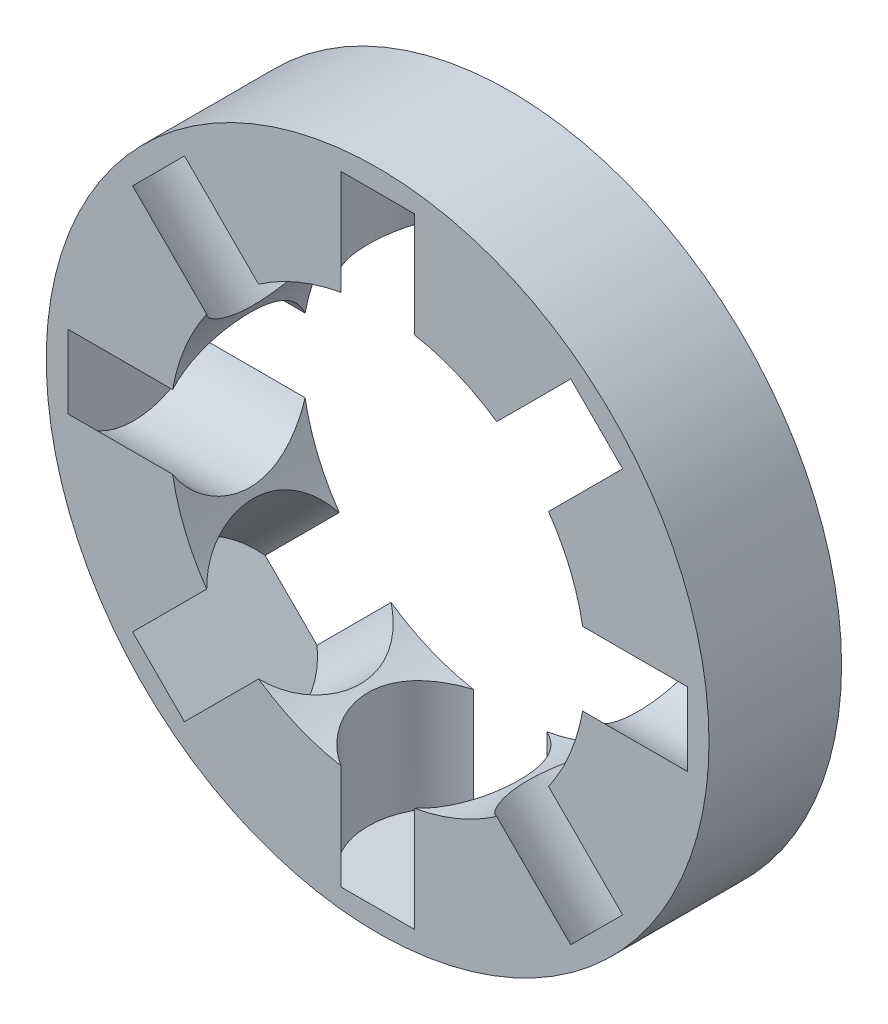
from build123d import *

# Parameters (mm, degrees)
SKETCH1_R           = 17.5
SKETCH1_R_2         = 11
BOSS_EXTRUDE1_DEPTH = 3.5
SKETCH4_R           = 4
CUT_EXTRUDE1_DEPTH  = 6.2
CIRPATTERN1_COUNT   = 8


with BuildPart() as part:
    # Sketch1 → Boss-Extrude1 (new, symmetric)
    with BuildSketch(Plane.XY):
        Circle(SKETCH1_R)
        Circle(SKETCH1_R_2, mode=Mode.SUBTRACT)
    extrude(amount=BOSS_EXTRUDE1_DEPTH, both=True)

    # Sketch4 → Cut-Extrude1 (cut)
    with BuildSketch(Plane(origin=(-10.162674858, 0, 0), x_dir=(0, 0, -1), z_dir=(1, 0, 0))):
        Circle(SKETCH4_R)
    cut_extrude1 = extrude(amount=-CUT_EXTRUDE1_DEPTH, mode=Mode.SUBTRACT)

    # CirPattern1: Cut-Extrude1 ×8 about axis
    cirpattern1_axis = Axis((0, 0, 3.5), (0, 0, -1))
    for i in range(1, CIRPATTERN1_COUNT):
        add(cut_extrude1.rotate(cirpattern1_axis, i * 360 / CIRPATTERN1_COUNT), mode=Mode.SUBTRACT)


solid = part.part
